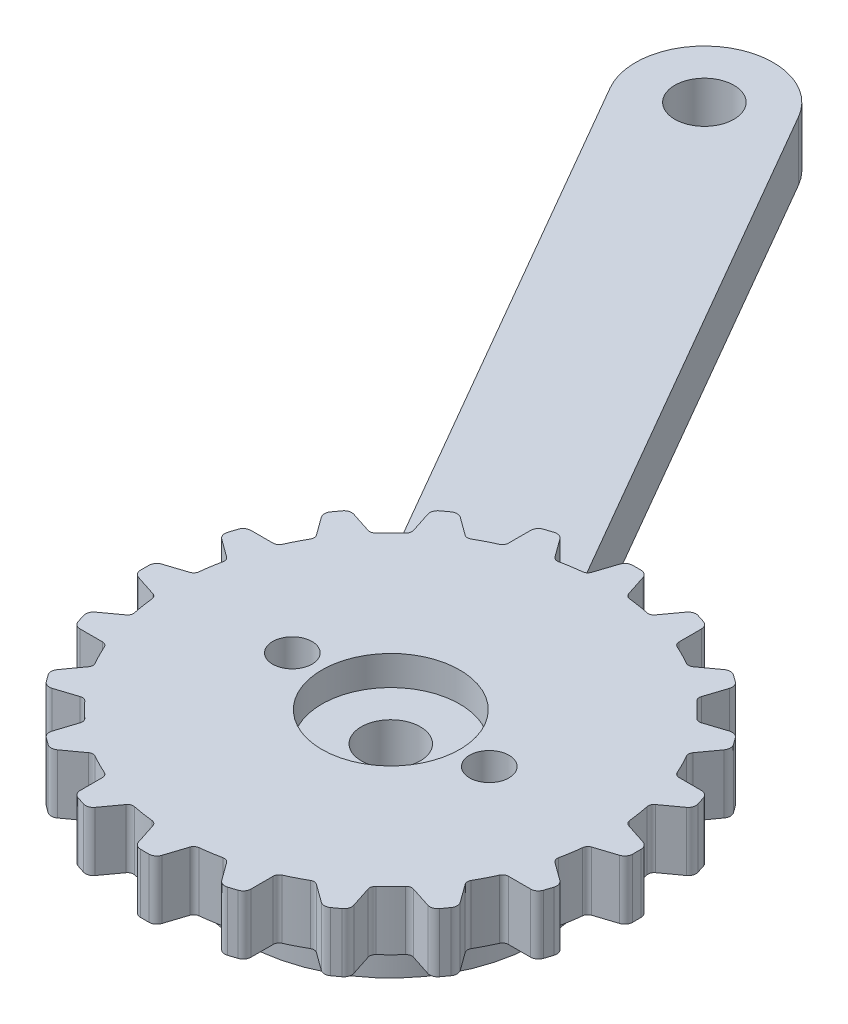
from build123d import *

# Parameters (mm, degrees)
SKETCH1_R                = 11
SKETCH1_R_2              = 1
SKETCH1_R_3              = 3.5
BOSS_EXTRUDE1_DEPTH      = 1.5
BOSS_EXTRUDE2_DEPTH      = 1.5
FILLET1_R                = 0.3
CIRPATTERN1_COUNT        = 20
FILLET1_OF_CIRPATTERN1_R = 0.3
BOSS_EXTRUDE3_START      = 3
BOSS_EXTRUDE3_DEPTH      = 3
SKETCH3_R                = 1.5
CUT_EXTRUDE1_DEPTH       = 49.391163816
SKETCH1_4_R              = 7.5
BOSS_EXTRUDE4_DEPTH      = 5
CUT_EXTRUDE2_DEPTH       = 49.733507317
CUT_EXTRUDE2_DEPTH_BACK  = 49.733507317
SKETCH4_R                = 1.5


with BuildPart() as part:
    # Sketch1 → Boss-Extrude1 (new, symmetric)
    with BuildSketch(Plane(origin=(0, 0, 0), x_dir=(1, 0, 0), z_dir=(0, 1, 0))):
        Circle(SKETCH1_R)
        with Locations((5, 0)):
            Circle(SKETCH1_R_2, mode=Mode.SUBTRACT)
        with Locations((-5, 0)):
            Circle(SKETCH1_R_2, mode=Mode.SUBTRACT)
        Circle(SKETCH1_R_3, mode=Mode.SUBTRACT)
    extrude(amount=BOSS_EXTRUDE1_DEPTH, both=True)

    # Sketch1_3 → Boss-Extrude2 (add, symmetric)
    with BuildSketch(Plane(origin=(0, 0, 0), x_dir=(1, 0, 0), z_dir=(0, 1, 0))):
        with BuildLine():
            Line((-0.589920274, 12.21384277), (-1, 10.95445115))
            ThreePointArc((-1, 10.95445115), (0, 11), (1, 10.95445115))
            Line((1, 10.95445115), (0.589920274, 12.21384277))
            ThreePointArc((0.589920274, 12.21384277), (0.444587735, 12.413676943), (0.209575724, 12.489995997))
            Line((0.209575724, 12.489995997), (-0.209575724, 12.489995997))
            ThreePointArc((-0.209575724, 12.489995997), (-0.444587735, 12.413676943), (-0.589920274, 12.21384277))
        make_face()
    boss_extrude2 = extrude(amount=BOSS_EXTRUDE2_DEPTH, both=True)

    # Fillet1
    fillet1_edges = [part.edges().sort_by_distance(p)[0] for p in [
        (1, 0, -10.95445115),
        (-1, 0, -10.95445115),
    ]]
    fillet(fillet1_edges, radius=FILLET1_R)

    # CirPattern1: Boss-Extrude2 ×20 about axis
    cirpattern1_axis = Axis((0, 1.5, 0), (0, 1, 0))
    for i in range(1, CIRPATTERN1_COUNT):
        add(boss_extrude2.rotate(cirpattern1_axis, i * 360 / CIRPATTERN1_COUNT))

    # Fillet1 of CirPattern1
    fillet1_of_cirpattern1_edges = [part.edges().sort_by_distance(p)[0] for p in [
        (-2.434055053, 0, -10.727319143),
        (-4.336168086, 0, -10.109285154),
        (-5.629847839, 0, -9.450122397),
        (-7.247881827, 0, -8.274551892),
        (-8.274551892, 0, -7.247881827),
        (-9.450122397, 0, -5.629847839),
        (-10.109285154, 0, -4.336168086),
        (-10.727319143, 0, -2.434055053),
        (-10.95445115, 0, -1),
        (-10.95445115, 0, 1),
        (-10.727319143, 0, 2.434055053),
        (-10.109285154, 0, 4.336168086),
        (-9.450122397, 0, 5.629847839),
        (-8.274551892, 0, 7.247881827),
        (-7.247881827, 0, 8.274551892),
        (-5.629847839, 0, 9.450122397),
        (-4.336168086, 0, 10.109285154),
        (-2.434055053, 0, 10.727319143),
        (-1, 0, 10.95445115),
        (1, 0, 10.95445115),
        (2.434055053, 0, 10.727319143),
        (4.336168086, 0, 10.109285154),
        (5.629847839, 0, 9.450122397),
        (7.247881827, 0, 8.274551892),
        (8.274551892, 0, 7.247881827),
        (9.450122397, 0, 5.629847839),
        (10.109285154, 0, 4.336168086),
        (10.727319143, 0, 2.434055053),
        (10.95445115, 0, 1),
        (10.95445115, 0, -1),
        (10.727319143, 0, -2.434055053),
        (10.109285154, 0, -4.336168086),
        (9.450122397, 0, -5.629847839),
        (8.274551892, 0, -7.247881827),
        (7.247881827, 0, -8.274551892),
        (5.629847839, 0, -9.450122397),
        (4.336168086, 0, -10.109285154),
        (2.434055053, 0, -10.727319143),
    ]]
    fillet(fillet1_of_cirpattern1_edges, radius=FILLET1_OF_CIRPATTERN1_R)

    # Sketch2 → Boss-Extrude3 (add)
    with BuildSketch(Plane.XZ.offset(1.5).offset(BOSS_EXTRUDE3_START)):
        with BuildLine():
            Line((-18.718911087, -39.422105065), (3.031088913, -1.75))
            ThreePointArc((3.031088913, -1.75), (-1.75, -3.031088913), (-3.031088913, 1.75))
            Line((-3.031088913, 1.75), (-24.781088913, -35.922105065))
            ThreePointArc((-24.781088913, -35.922105065), (-23.5, -40.703193978), (-18.718911087, -39.422105065))
        make_face()
    extrude(amount=-BOSS_EXTRUDE3_DEPTH)

    # Sketch3 → Cut-Extrude1 (cut, through all)
    with BuildSketch(Plane(origin=(0, -1.5, 0), x_dir=(1, 0, 0), z_dir=(0, 1, 0))):
        with Locations((-21.75, 37.672105065)):
            Circle(SKETCH3_R)
    extrude(amount=-CUT_EXTRUDE1_DEPTH, mode=Mode.SUBTRACT)

    # Sketch1_4 → Boss-Extrude4 (add)
    with BuildSketch(Plane(origin=(0, 0, 0), x_dir=(1, 0, 0), z_dir=(0, 1, 0))):
        Circle(SKETCH1_4_R)
    extrude(amount=-BOSS_EXTRUDE4_DEPTH)

    # Sketch4 → Cut-Extrude2 (cut, two sides: drawn at the far end of the back side and taken through both)
    with BuildSketch(Plane.XZ.offset(5).offset(-CUT_EXTRUDE2_DEPTH_BACK)):
        Circle(SKETCH4_R)
    extrude(amount=CUT_EXTRUDE2_DEPTH + CUT_EXTRUDE2_DEPTH_BACK, mode=Mode.SUBTRACT)


solid = part.part
